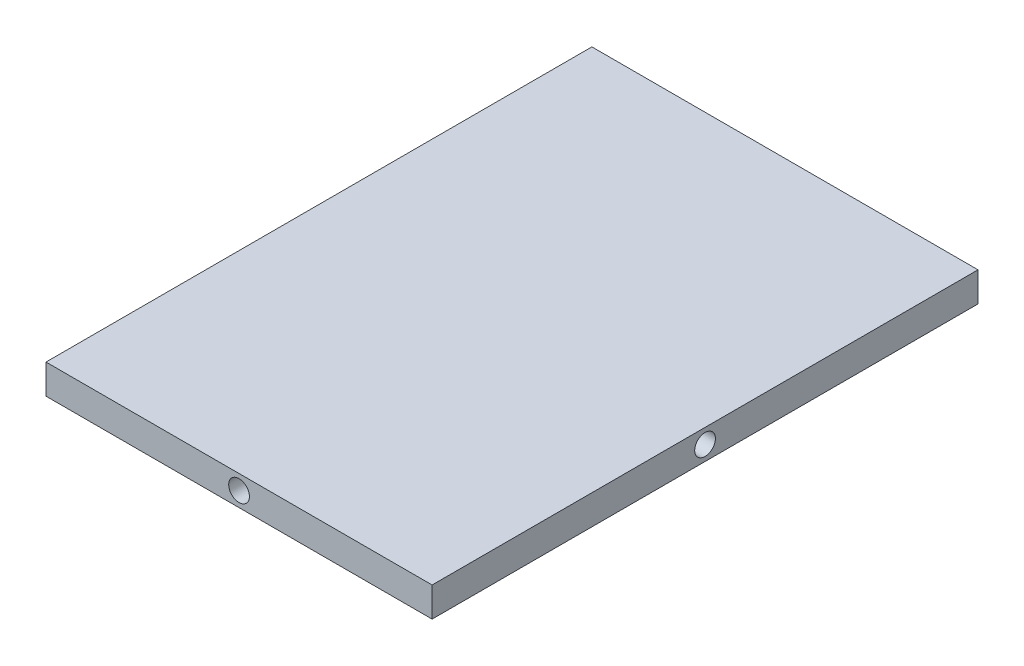
from build123d import *

# Parameters (mm, degrees)
SKETCH_1_W          = 130.5
SKETCH_1_H          = 184.5
EXTRUDE_1_DEPTH     = 10
SKETCH_2_R          = 3.5
CUT_EXTRUDE_1_DEPTH = 10
SKETCH_3_R          = 3.5
CUT_EXTRUDE_2_DEPTH = 10
CUT_EXTRUDE_3_DEPTH = 10
SKETCH_5_R          = 3.5
CUT_EXTRUDE_4_DEPTH = 10


with BuildPart() as part:
    # 草图1 → 凸台-拉伸1 (new body)
    with BuildSketch(Plane(origin=(0, 0, 0), x_dir=(1, 0, 0), z_dir=(0, 1, 0))):
        Rectangle(SKETCH_1_W, SKETCH_1_H)
    extrude(amount=EXTRUDE_1_DEPTH)

    # 草图2 → 切除-拉伸1 (cut)
    with BuildSketch(Plane.XY.offset(92.25)):
        with Locations((0, 5)):
            Circle(SKETCH_2_R)
    extrude(amount=-CUT_EXTRUDE_1_DEPTH, mode=Mode.SUBTRACT)

    # 草图3 → 切除-拉伸2 (cut)
    with BuildSketch(Plane(origin=(65.25, 0, 0), x_dir=(0, 0, -1), z_dir=(1, 0, 0))):
        with Locations((0, 5)):
            Circle(SKETCH_3_R)
    extrude(amount=-CUT_EXTRUDE_2_DEPTH, mode=Mode.SUBTRACT)

    # 草图4 → 切除-拉伸3 (cut)
    with BuildSketch(Plane(origin=(0, 0, -92.25), x_dir=(-1, 0, 0), z_dir=(0, 0, -1))):
        with BuildLine():
            ThreePointArc((3.489769201, 5.267415264), (0, 8.5), (-3.489769201, 5.267415264))
            Line((-3.489769201, 5.267415264), (0, 5))
            Line((0, 5), (3.489769201, 5.267415264))
        make_face()
        with BuildLine():
            Line((0, 5), (-3.489769201, 5.267415264))
            ThreePointArc((-3.489769201, 5.267415264), (-3.5, 5), (-3.489769201, 4.732584736))
            Line((-3.489769201, 4.732584736), (0, 5))
        make_face()
        with BuildLine():
            Line((3.489769201, 5.267415264), (0, 5))
            Line((0, 5), (3.489769201, 4.732584736))
            ThreePointArc((3.489769201, 4.732584736), (3.497441365, 4.866194551), (3.5, 5))
            ThreePointArc((3.5, 5), (3.497441365, 5.133805449), (3.489769201, 5.267415264))
        make_face()
        with BuildLine():
            Line((3.489769201, 4.732584736), (0, 5))
            Line((0, 5), (-3.489769201, 4.732584736))
            ThreePointArc((-3.489769201, 4.732584736), (0, 1.5), (3.489769201, 4.732584736))
        make_face()
    extrude(amount=-CUT_EXTRUDE_3_DEPTH, mode=Mode.SUBTRACT)

    # 草图5 → 切除-拉伸4 (cut)
    with BuildSketch(Plane.ZY.offset(65.25)):
        with Locations((0, 5)):
            Circle(SKETCH_5_R)
    extrude(amount=-CUT_EXTRUDE_4_DEPTH, mode=Mode.SUBTRACT)


solid = part.part
